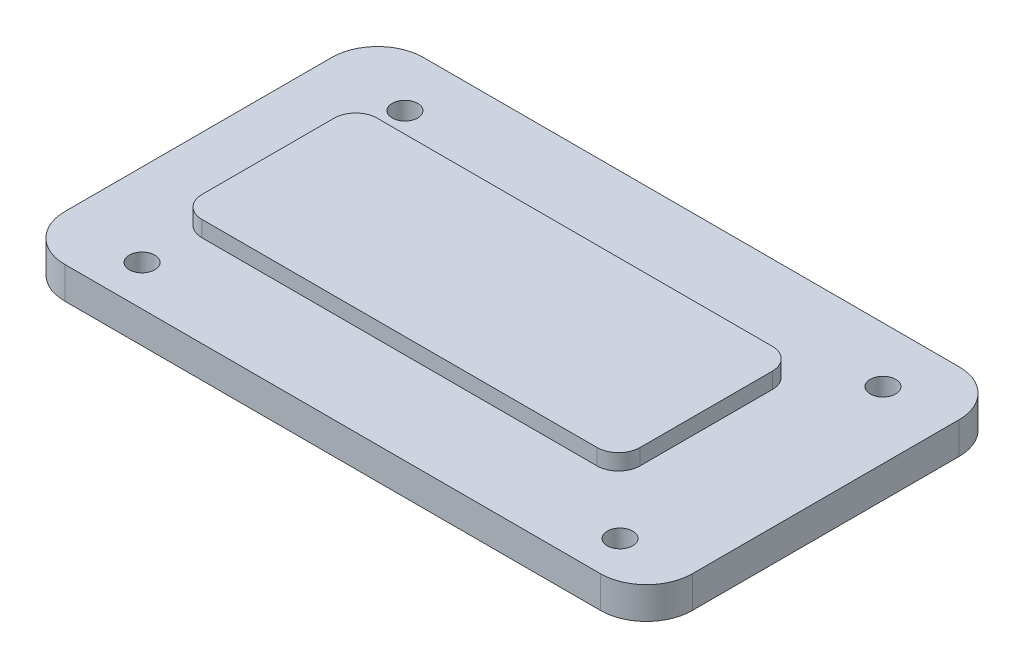
from build123d import *

# Parameters (mm, degrees)
BOSS_EXTRUDE1_DEPTH = 3
CUT_EXTRUDE1_START  = -1
CUT_EXTRUDE1_DEPTH  = 1
SKETCH3_R           = 0.8
CUT_EXTRUDE2_DEPTH  = 25.230662393


with BuildPart() as part:
    # Sketch1 → Boss-Extrude1 (new body)
    with BuildSketch(Plane(origin=(0, 0, 0), x_dir=(1, 0, 0), z_dir=(0, 1, 0))):
        with BuildLine():
            Line((21.25, -8.375), (21.25, 8.375))
            ThreePointArc((21.25, 8.375), (20.407931996, 10.407931996), (18.375, 11.25))
            Line((18.375, 11.25), (-15.25, 11.25))
            ThreePointArc((-15.25, 11.25), (-17.282931996, 10.407931996), (-18.125, 8.375))
            Line((-18.125, 8.375), (-18.125, -8.375))
            ThreePointArc((-18.125, -8.375), (-17.282931996, -10.407931996), (-15.25, -11.25))
            Line((-15.25, -11.25), (18.375, -11.25))
            ThreePointArc((18.375, -11.25), (20.407931996, -10.407931996), (21.25, -8.375))
        make_face()
    extrude(amount=BOSS_EXTRUDE1_DEPTH)

    # Sketch2 → Cut-Extrude1 (cut)
    with BuildSketch(Plane(origin=(0, 3, 0), x_dir=(1, 0, 0), z_dir=(0, 1, 0)).offset(CUT_EXTRUDE1_START)):
        with BuildLine():
            ThreePointArc((18.375, -11.25), (20.407931996, -10.407931996), (21.25, -8.375))
            Line((21.25, -8.375), (21.25, 8.375))
            ThreePointArc((21.25, 8.375), (20.407931996, 10.407931996), (18.375, 11.25))
            Line((18.375, 11.25), (-15.25, 11.25))
            ThreePointArc((-15.25, 11.25), (-17.282931996, 10.407931996), (-18.125, 8.375))
            Line((-18.125, 8.375), (-18.125, -8.375))
            ThreePointArc((-18.125, -8.375), (-17.282931996, -10.407931996), (-15.25, -11.25))
            Line((-15.25, -11.25), (18.375, -11.25))
        make_face()
        with BuildLine():
            Line((-13.75, -4.15), (-13.75, 4.15))
            ThreePointArc((-13.75, 4.15), (-13.354594155, 5.104594155), (-12.4, 5.5))
            Line((-12.4, 5.5), (12.4, 5.5))
            ThreePointArc((12.4, 5.5), (13.354594155, 5.104594155), (13.75, 4.15))
            Line((13.75, 4.15), (13.75, -4.15))
            ThreePointArc((13.75, -4.15), (13.354594155, -5.104594155), (12.4, -5.5))
            Line((12.4, -5.5), (-12.4, -5.5))
            ThreePointArc((-12.4, -5.5), (-13.354594155, -5.104594155), (-13.75, -4.15))
        make_face(mode=Mode.SUBTRACT)
    extrude(amount=CUT_EXTRUDE1_DEPTH, mode=Mode.SUBTRACT)

    # Sketch3 → Cut-Extrude2 (cut, through all)
    with BuildSketch(Plane.XZ):
        with Locations((17.064715841, -7.779032038)):
            Circle(SKETCH3_R)
        with Locations((-12.935284159, -7.779032038)):
            Circle(SKETCH3_R)
        with Locations((-12.935284159, 8.720967962)):
            Circle(SKETCH3_R)
        with Locations((17.064715841, 8.720967962)):
            Circle(SKETCH3_R)
    extrude(amount=-CUT_EXTRUDE2_DEPTH, mode=Mode.SUBTRACT)


solid = part.part
